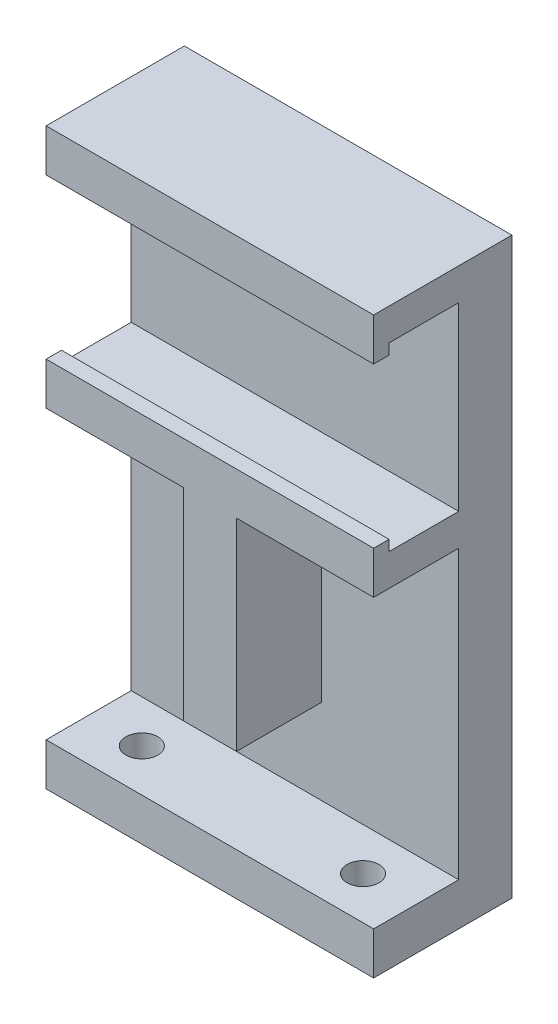
from build123d import *

# Parameters (mm, degrees)
SKETCH_1_W          = 30.8
SKETCH_1_H          = 42
EXTRUDE_1_DEPTH     = 5
SKETCH_2_W          = 30.8
SKETCH_2_H          = 3
EXTRUDE_2_DEPTH     = 8
SKETCH_3_W          = 5
SKETCH_3_H          = 19
EXTRUDE_3_DEPTH     = 8
EXTRUDE_4_DEPTH     = 30.8
CUT_EXTRUDE_1_REACH = 6
SKETCH_5_R          = 1.5
SKETCH_6_W          = 1.45
SKETCH_6_H          = 1
EXTRUDE_5_DEPTH     = 30.8


with BuildPart() as part:
    # 草图1 → 凸台-拉伸1 (new body)
    with BuildSketch(Plane.XY):
        with Locations((15.4, 21)):
            Rectangle(SKETCH_1_W, SKETCH_1_H)
    extrude(amount=EXTRUDE_1_DEPTH)

    # 草图2 → 凸台-拉伸2 (add)
    with BuildSketch(Plane.XY.offset(5)):
        with Locations((15.4, 40.5)):
            Rectangle(SKETCH_2_W, SKETCH_2_H)
        with Locations((15.4, 20.5)):
            Rectangle(SKETCH_2_W, SKETCH_2_H)
    extrude(amount=EXTRUDE_2_DEPTH)

    # 草图3 → 凸台-拉伸3 (add)
    with BuildSketch(Plane.XY.offset(5)):
        with Locations((15.4, 9.5)):
            Rectangle(SKETCH_3_W, SKETCH_3_H)
    extrude(amount=EXTRUDE_3_DEPTH)

    # 草图4 → 凸台-拉伸4 (add)
    with BuildSketch(Plane(origin=(30.8, 0, 0), x_dir=(0, 0, -1), z_dir=(1, 0, 0))):
        Polygon((-5, 0), (-5, -8), (-13, -8), (-13, -12), (0, -12), (0, 0), align=None)
    extrude(amount=-EXTRUDE_4_DEPTH)

    # 草图5 → 切除-拉伸1 (cut, up to next)
    with BuildSketch(Plane(origin=(0, -8, 0), x_dir=(1, 0, 0), z_dir=(0, 1, 0)), mode=Mode.PRIVATE) as cut_extrude_1_sk1:
        with Locations((5, -9)):
            Circle(SKETCH_5_R)
    cut_extrude_1_tool1 = extrude(cut_extrude_1_sk1.sketch, amount=-CUT_EXTRUDE_1_REACH, mode=Mode.PRIVATE) & part.part
    add(cut_extrude_1_tool1.solids().sort_by_distance((5, -8, 9))[0], mode=Mode.SUBTRACT)
    # 草图5 → 切除-拉伸1 (cut, up to next)
    with BuildSketch(Plane(origin=(0, -8, 0), x_dir=(1, 0, 0), z_dir=(0, 1, 0)), mode=Mode.PRIVATE) as cut_extrude_1_sk2:
        with Locations((25.8, -9)):
            Circle(SKETCH_5_R)
    cut_extrude_1_tool2 = extrude(cut_extrude_1_sk2.sketch, amount=-CUT_EXTRUDE_1_REACH, mode=Mode.PRIVATE) & part.part
    add(cut_extrude_1_tool2.solids().sort_by_distance((25.8, -8, 9))[0], mode=Mode.SUBTRACT)

    # 草图6 → 凸台-拉伸5 (add, through all)
    with BuildSketch(Plane(origin=(30.8, 0, 0), x_dir=(0, 0, -1), z_dir=(1, 0, 0))):
        with Locations((-12.275, 38.5)):
            Rectangle(SKETCH_6_W, SKETCH_6_H)
        with Locations((-12.275, 22.5)):
            Rectangle(SKETCH_6_W, SKETCH_6_H)
    extrude(amount=-EXTRUDE_5_DEPTH)


solid = part.part
